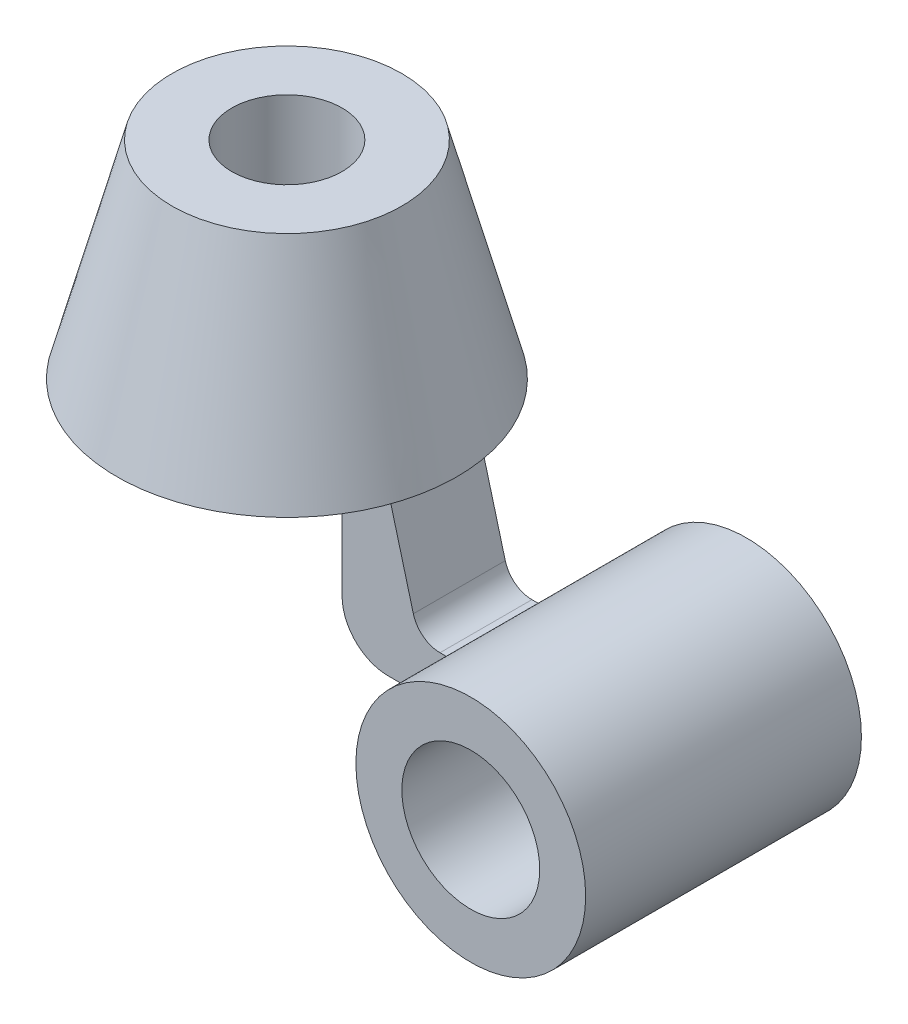
from build123d import *

# Parameters (mm, degrees)
BOSS_EXTRUDE1_DEPTH      = 30
BOSS_EXTRUDE1_DEPTH_BACK = 30
SKETCH2_R                = 25
BOSS_EXTRUDE2_DEPTH      = 10
BOSS_EXTRUDE2_DEPTH_BACK = 10
FILLET1_R                = 10
FILLET2_R                = 6
F_1_0MM_DOWEL_HOLE1_D    = 24
F_1_0MM_DOWEL_HOLE2_D    = 30


with BuildPart() as part:
    # Sketch1 → Revolve1 (revolve)
    with BuildSketch(Plane.XY):
        Polygon((0, 0), (0, 45), (25, 45), (37, 0), align=None)
    revolve(axis=Axis((0, 0, 0), (0, 1, 0)))



with BuildPart() as body_2:
    # Sketch2 → Boss-Extrude1 (new, two sides: drawn at the far end of the back side and taken through both)
    with BuildSketch(Plane.XY.offset(-BOSS_EXTRUDE1_DEPTH_BACK)):
        with Locations((70, -35)):
            Circle(SKETCH2_R)
    extrude(amount=BOSS_EXTRUDE1_DEPTH + BOSS_EXTRUDE1_DEPTH_BACK)


with BuildPart() as part_1:
    add(part.part)

    add(body_2.part)  # Boss-Extrude2 merges body 2
    # Sketch3 → Boss-Extrude2 (add, two sides: drawn at the far end of the back side and taken through both)
    with BuildSketch(Plane.XY.offset(-BOSS_EXTRUDE2_DEPTH_BACK)):
        Polygon((22, 0), (22, -35), (74.473929912, -35), (74.473929912, -25), (38.698729811, -25), (32, 0), align=None)
    extrude(amount=BOSS_EXTRUDE2_DEPTH + BOSS_EXTRUDE2_DEPTH_BACK)

    # Fillet1
    fillet1_edges = [part_1.edges().sort_by_distance(p)[0] for p in [
        (22, -35, 0),
    ]]
    fillet(fillet1_edges, radius=FILLET1_R)

    # Fillet2
    fillet2_edges = [part_1.edges().sort_by_distance(p)[0] for p in [
        (38.698729811, -25, 0),
    ]]
    fillet(fillet2_edges, radius=FILLET2_R)

    # Ø1.0mm Dowel Hole1 (through all)
    with Locations(Plane(origin=(0, 45, 0), x_dir=(1, 0, 0), z_dir=(0, 1, 0))):
        with Locations((0, 0)):
            Hole(F_1_0MM_DOWEL_HOLE1_D / 2)

    # Ø1.0mm Dowel Hole2 (through all)
    with Locations(Plane.XY.offset(30)):
        with Locations((70, -35)):
            Hole(F_1_0MM_DOWEL_HOLE2_D / 2)


solid = part_1.part
